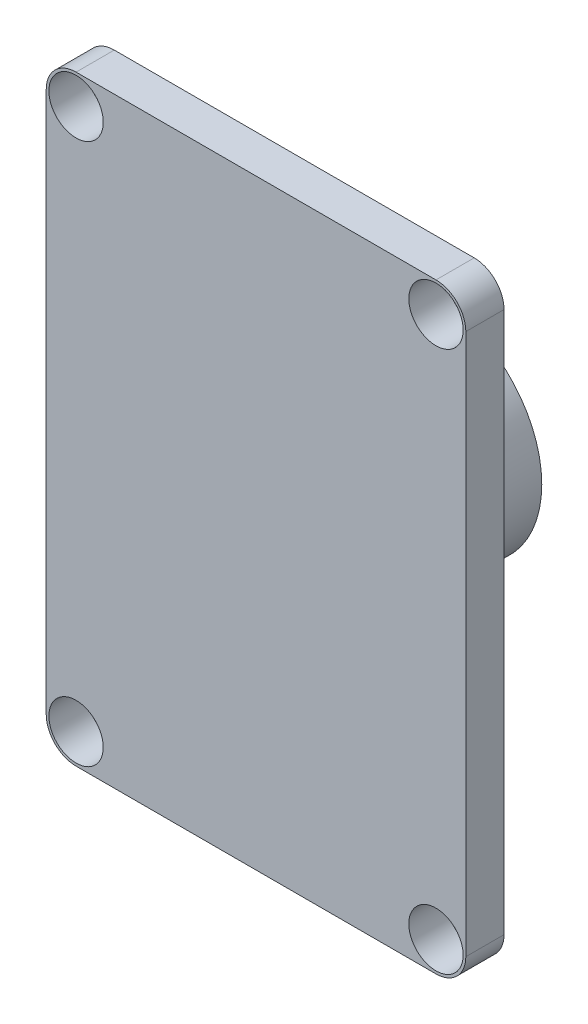
from build123d import *

# Parameters (mm, degrees)
SKETCH2_R           = 1.156401536
BOSS_EXTRUDE1_DEPTH = 1.6256
SKETCH3_R           = 4.65455
BOSS_EXTRUDE2_DEPTH = 5.8801


with BuildPart() as part:
    # Sketch2 → Boss-Extrude1 (new body)
    with BuildSketch(Plane.XY):
        with BuildLine():
            Line((-7.6581, -12.7889), (7.6581, -12.7889))
            ThreePointArc((7.6581, -12.7889), (8.556125612, -12.416925612), (8.9281, -11.5189))
            Line((8.9281, -11.5189), (8.9281, 11.5189))
            ThreePointArc((8.9281, 11.5189), (8.556125612, 12.416925612), (7.6581, 12.7889))
            Line((7.6581, 12.7889), (-7.6581, 12.7889))
            ThreePointArc((-7.6581, 12.7889), (-8.556125612, 12.416925612), (-8.9281, 11.5189))
            Line((-8.9281, 11.5189), (-8.9281, -11.5189))
            ThreePointArc((-8.9281, -11.5189), (-8.556125612, -12.416925612), (-7.6581, -12.7889))
        make_face()
        with Locations((7.6581, 11.5189)):
            Circle(SKETCH2_R, mode=Mode.SUBTRACT)
        with Locations((-7.6581, 11.5189)):
            Circle(SKETCH2_R, mode=Mode.SUBTRACT)
        with Locations((7.6581, -11.5189)):
            Circle(SKETCH2_R, mode=Mode.SUBTRACT)
        with Locations((-7.6581, -11.5189)):
            Circle(SKETCH2_R, mode=Mode.SUBTRACT)
    extrude(amount=BOSS_EXTRUDE1_DEPTH)

    # Sketch3 → Boss-Extrude2 (add)
    with BuildSketch(Plane(origin=(0, 0, 0), x_dir=(-1, 0, 0), z_dir=(0, 0, -1))):
        Circle(SKETCH3_R)
    extrude(amount=BOSS_EXTRUDE2_DEPTH)


solid = part.part
